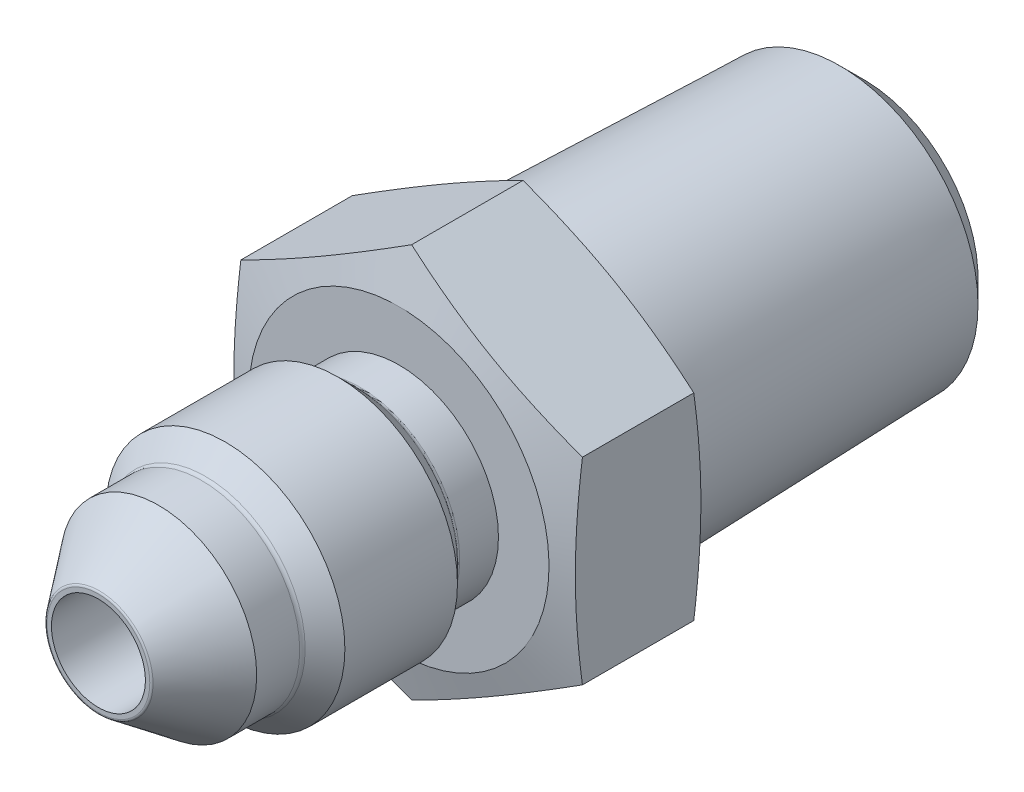
from build123d import *

# Parameters (mm, degrees)
BOSS_EXTRUDE1_DEPTH      = 3.81
BOSS_EXTRUDE1_DEPTH_BACK = 2.54
SKETCH6_R                = 6.858
BOSS_EXTRUDE2_DEPTH      = 15.10284
BOSS_EXTRUDE2_TAPER      = 1.783333333
SKETCH9_OUTSIDE_W        = 56.69
SKETCH9_OUTSIDE_H        = 59.144
SKETCH9_OUTSIDE_R        = 5.318470858
CUT_EXTRUDE1_DEPTH       = 15.10284
CUT_EXTRUDE1_TAPER       = 45
SKETCH10_R               = 6.858
BOSS_EXTRUDE3_DEPTH      = 0.13716
SKETCH11_W               = 35.56
SKETCH11_H               = 2.1844


with BuildPart() as part:
    # Sketch1 → Revolve1 (revolve)
    with BuildSketch(Plane(origin=(0, 0, 0), x_dir=(0, 0, -1), z_dir=(1, 0, 0))):
        with BuildLine():
            Line((-17.78, 0), (0, 0))
            Line((0, 0), (0, 4.6228))
            Line((0, 4.6228), (-5.609789755, 4.6228))
            ThreePointArc((-5.609789755, 4.6228), (-5.706991347, 4.642134599), (-5.789394878, 4.697194878))
            Line((-5.789394878, 4.697194878), (-6.64845, 5.55625))
            Line((-6.64845, 5.55625), (-11.88085, 5.55625))
            Line((-11.88085, 5.55625), (-12.803405122, 4.633694878))
            ThreePointArc((-12.803405122, 4.633694878), (-12.885808653, 4.578634599), (-12.983010245, 4.5593))
            Line((-12.983010245, 4.5593), (-14.982324107, 4.5593))
            Line((-14.982324107, 4.5593), (-17.729430508, 2.489206846))
            ThreePointArc((-17.729430508, 2.489206846), (-17.766656664, 2.444447258), (-17.78, 2.387780136))
            Line((-17.78, 2.387780136), (-17.78, 0))
        make_face()
    revolve(axis=Axis((0, 0, 19.812), (0, 0, -1)))

    # Sketch4 → Boss-Extrude1 (add, two sides)
    with BuildSketch(Plane.XY) as boss_extrude1_sk:
        Polygon((0, 9.165435523), (-7.9375, 4.582717762), (-7.9375, -4.582717762), (0, -9.165435523), (7.9375, -4.582717762), (7.9375, 4.582717762), align=None)
    extrude(amount=BOSS_EXTRUDE1_DEPTH)
    extrude(boss_extrude1_sk.sketch, amount=-BOSS_EXTRUDE1_DEPTH_BACK)

    # Sketch5 → Cut-Revolve1 (revolve, cut)
    with BuildSketch(Plane(origin=(0, 0, 0), x_dir=(0, 0, -1), z_dir=(1, 0, 0))):
        Polygon((-3.81, 11.358571047), (2.54, 11.358571047), (2.54, 6.9723), (1.952351108, 9.165435523), (-3.222351108, 9.165435523), (-3.81, 6.9723), align=None)
    revolve(axis=Axis((0, 0, 3.81), (0, 0, -1)), mode=Mode.SUBTRACT)



with BuildPart() as body_2:
    # Sketch6 → Boss-Extrude2 (new body)
    with BuildSketch(Plane.XY.offset(-2.67716)):
        Circle(SKETCH6_R)
    extrude(amount=-BOSS_EXTRUDE2_DEPTH, taper=BOSS_EXTRUDE2_TAPER)

    # Sketch9 outside → Cut-Extrude1 (cut)
    with BuildSketch(Plane(origin=(0, 0, -17.78), x_dir=(-1, 0, 0), z_dir=(0, 0, -1))):
        Rectangle(SKETCH9_OUTSIDE_W, SKETCH9_OUTSIDE_H)
        Circle(SKETCH9_OUTSIDE_R, mode=Mode.SUBTRACT)
    extrude(amount=-CUT_EXTRUDE1_DEPTH, taper=CUT_EXTRUDE1_TAPER, mode=Mode.SUBTRACT)


with BuildPart() as part_1:
    add(part.part)

    add(body_2.part)  # Boss-Extrude3 merges body 2
    # Sketch10 → Boss-Extrude3 (add)
    with BuildSketch(Plane.XY.offset(-2.67716)):
        Circle(SKETCH10_R)
    extrude(amount=BOSS_EXTRUDE3_DEPTH)

    # Sketch11 → Cut-Revolve2 (revolve, cut)
    with BuildSketch(Plane(origin=(0, 0, 0), x_dir=(0, 0, -1), z_dir=(1, 0, 0))):
        with Locations((0, 1.0922)):
            Rectangle(SKETCH11_W, SKETCH11_H)
    revolve(axis=Axis((0, 0, -17.78), (0, 0, 1)), mode=Mode.SUBTRACT)

    # Sketch12 → Cut-Revolve3 (revolve, cut)
    with BuildSketch(Plane(origin=(0, 0, 0), x_dir=(0, 0, -1), z_dir=(1, 0, 0))):
        Polygon((17.78, 0), (-2.289278958, 0), (0, 3.81), (17.78, 3.81), align=None)
    revolve(axis=Axis((0, 0, 17.78), (0, 0, -1)), mode=Mode.SUBTRACT)


solid = part_1.part
